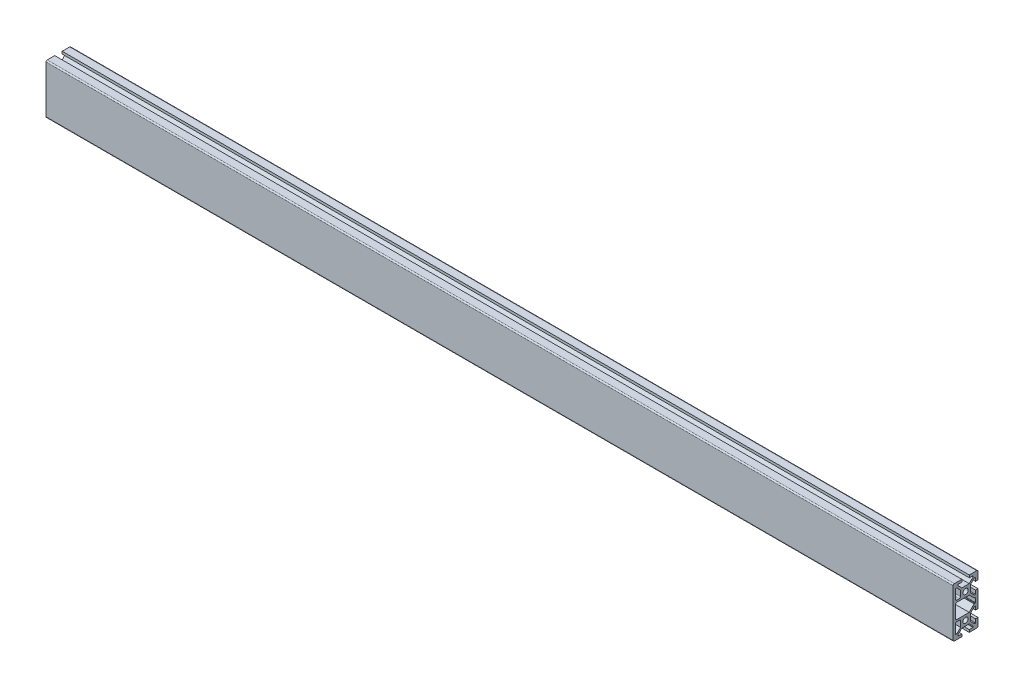
from build123d import *

# Parameters (mm, degrees)
SKETCH1_R           = 2.1
BOSS_EXTRUDE1_DEPTH = 729


with BuildPart() as part:
    # Sketch1 → Boss-Extrude1 (new body)
    with BuildSketch(Plane(origin=(0, 0, 0), x_dir=(0, 0, -1), z_dir=(1, 0, 0))):
        with BuildLine():
            Line((10, 13), (10, 19))
            ThreePointArc((10, 19), (9.707106781, 19.707106781), (9, 20))
            Line((9, 20), (3, 20))
            Line((3, 20), (3, 18))
            Line((3, 18), (6, 18))
            Line((6, 18), (6, 17.060660172))
            Line((6, 17.060660172), (2.939339828, 14))
            Line((2.939339828, 14), (-2.939339828, 14))
            Line((-2.939339828, 14), (-6, 17.060660172))
            Line((-6, 17.060660172), (-6, 18))
            Line((-6, 18), (-3, 18))
            Line((-3, 18), (-3, 20))
            Line((-3, 20), (-9, 20))
            ThreePointArc((-9, 20), (-9.707106781, 19.707106781), (-10, 19))
            Line((-10, 19), (-10, -19))
            ThreePointArc((-10, -19), (-9.707106781, -19.707106781), (-9, -20))
            Line((-9, -20), (-3, -20))
            Line((-3, -20), (-3, -18))
            Line((-3, -18), (-6, -18))
            Line((-6, -18), (-6, -17.060660172))
            Line((-6, -17.060660172), (-2.939339828, -14))
            Line((-2.939339828, -14), (2.939339828, -14))
            Line((2.939339828, -14), (6, -17.060660172))
            Line((6, -17.060660172), (6, -18))
            Line((6, -18), (3, -18))
            Line((3, -18), (3, -20))
            Line((3, -20), (9, -20))
            ThreePointArc((9, -20), (9.707106781, -19.707106781), (10, -19))
            Line((10, -19), (10, -13))
            Line((10, -13), (8, -13))
            Line((8, -13), (8, -16))
            Line((8, -16), (7.060660172, -16))
            Line((7.060660172, -16), (4, -12.939339828))
            Line((4, -12.939339828), (4, -7.060660172))
            Line((4, -7.060660172), (7.060660172, -4))
            Line((7.060660172, -4), (8, -4))
            Line((8, -4), (8, -7))
            Line((8, -7), (10, -7))
            Line((10, -7), (10, 7))
            Line((10, 7), (8, 7))
            Line((8, 7), (8, 4))
            Line((8, 4), (7.060660172, 4))
            Line((7.060660172, 4), (4, 7.060660172))
            Line((4, 7.060660172), (4, 12.939339828))
            Line((4, 12.939339828), (7.060660172, 16))
            Line((7.060660172, 16), (8, 16))
            Line((8, 16), (8, 13))
            Line((8, 13), (10, 13))
        make_face()
        with Locations((0, -10)):
            Circle(SKETCH1_R, mode=Mode.SUBTRACT)
        with Locations((0, 10)):
            Circle(SKETCH1_R, mode=Mode.SUBTRACT)
        with BuildLine():
            Line((8, -1.7), (8, 1.7))
            ThreePointArc((8, 1.7), (7.912132034, 1.912132034), (7.7, 2))
            Line((7.7, 2), (7.063603897, 2))
            ThreePointArc((7.063603897, 2), (6.948798867, 2.02283614), (6.851471863, 2.087867966))
            Line((6.851471863, 2.087867966), (2.939339828, 6))
            Line((2.939339828, 6), (-7, 6))
            ThreePointArc((-7, 6), (-7.707106781, 5.707106781), (-8, 5))
            Line((-8, 5), (-8, -5))
            ThreePointArc((-8, -5), (-7.707106781, -5.707106781), (-7, -6))
            Line((-7, -6), (2.939339828, -6))
            Line((2.939339828, -6), (6.851471863, -2.087867966))
            ThreePointArc((6.851471863, -2.087867966), (6.948798867, -2.02283614), (7.063603897, -2))
            Line((7.063603897, -2), (7.7, -2))
            ThreePointArc((7.7, -2), (7.912132034, -1.912132034), (8, -1.7))
        make_face(mode=Mode.SUBTRACT)
        with BuildLine():
            Line((-7.060660172, -16), (-4, -12.939339828))
            Line((-4, -12.939339828), (-4, -8.5))
            ThreePointArc((-4, -8.5), (-4.292893219, -7.792893219), (-5, -7.5))
            Line((-5, -7.5), (-7, -7.5))
            ThreePointArc((-7, -7.5), (-7.707106781, -7.792893219), (-8, -8.5))
            Line((-8, -8.5), (-8, -16))
            Line((-8, -16), (-7.060660172, -16))
        make_face(mode=Mode.SUBTRACT)
        with BuildLine():
            Line((-4, 8.5), (-4, 12.939339828))
            Line((-4, 12.939339828), (-7.060660172, 16))
            Line((-7.060660172, 16), (-8, 16))
            Line((-8, 16), (-8, 8.5))
            ThreePointArc((-8, 8.5), (-7.707106781, 7.792893219), (-7, 7.5))
            Line((-7, 7.5), (-5, 7.5))
            ThreePointArc((-5, 7.5), (-4.292893219, 7.792893219), (-4, 8.5))
        make_face(mode=Mode.SUBTRACT)
    extrude(amount=BOSS_EXTRUDE1_DEPTH)


solid = part.part
